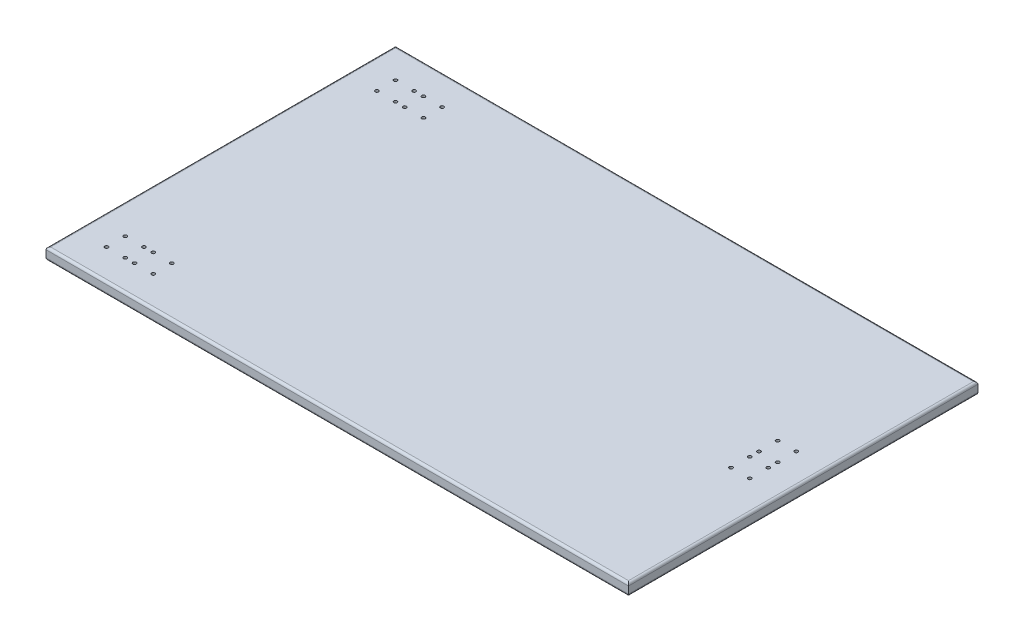
from build123d import *

# Parameters (mm, degrees)
ESQUISSE1_W             = 2500
ESQUISSE1_H             = 1500
BOSS_EXTRU_1_DEPTH      = 50
CONG_1_R                = 10
CONG_2_R                = 10
ESQUISSE4_R             = 7.25
ENL_V_MAT_EXTRU_2_DEPTH = 51
ESQUISSE5_R             = 7.25
ENL_V_MAT_EXTRU_3_DEPTH = 51


with BuildPart() as part:
    # Esquisse1 → Boss.-Extru.1 (new body)
    with BuildSketch(Plane(origin=(0, 0, 0), x_dir=(1, 0, 0), z_dir=(0, 1, 0))):
        Rectangle(ESQUISSE1_W, ESQUISSE1_H)
    extrude(amount=BOSS_EXTRU_1_DEPTH)

    # Congé1
    cong_1_edges = [part.edges().sort_by_distance(p)[0] for p in [
        (1250, 50, 0),
        (0, 50, -750),
        (-1250, 50, 0),
        (0, 50, 750),
    ]]
    fillet(cong_1_edges, radius=CONG_1_R)

    # Congé2
    cong_2_edges = [part.edges().sort_by_distance(p)[0] for p in [
        (0, 0, -750),
        (1250, 0, 0),
        (0, 0, 750),
        (-1250, 0, 0),
    ]]
    fillet(cong_2_edges, radius=CONG_2_R)

    # Esquisse4 → Enlèv. mat.-Extru.2 (cut, through all)
    with BuildSketch(Plane.XZ):
        with Locations((1120, -100)):
            Circle(ESQUISSE4_R)
        with Locations((1040, -100)):
            Circle(ESQUISSE4_R)
        with Locations((1040, -20)):
            Circle(ESQUISSE4_R)
        with Locations((1120, -20)):
            Circle(ESQUISSE4_R)
        with Locations((1120, 100)):
            Circle(ESQUISSE4_R)
        with Locations((1120, 20)):
            Circle(ESQUISSE4_R)
        with Locations((1040, 20)):
            Circle(ESQUISSE4_R)
        with Locations((1040, 100)):
            Circle(ESQUISSE4_R)
    extrude(amount=-ENL_V_MAT_EXTRU_2_DEPTH, mode=Mode.SUBTRACT)

    # Esquisse5 → Enlèv. mat.-Extru.3 (cut, through all)
    with BuildSketch(Plane(origin=(0, 0, 0), x_dir=(-1, 0, 0), z_dir=(0, -1, 0))):
        with Locations((1120, 620)):
            Circle(ESQUISSE5_R)
        with Locations((1040, 620)):
            Circle(ESQUISSE5_R)
        with Locations((1040, 540)):
            Circle(ESQUISSE5_R)
        with Locations((1120, 540)):
            Circle(ESQUISSE5_R)
        with Locations((920, 620)):
            Circle(ESQUISSE5_R)
        with Locations((1000, 620)):
            Circle(ESQUISSE5_R)
        with Locations((1000, 540)):
            Circle(ESQUISSE5_R)
        with Locations((920, 540)):
            Circle(ESQUISSE5_R)
        with Locations((920, -620)):
            Circle(ESQUISSE5_R)
        with Locations((920, -540)):
            Circle(ESQUISSE5_R)
        with Locations((1000, -540)):
            Circle(ESQUISSE5_R)
        with Locations((1000, -620)):
            Circle(ESQUISSE5_R)
        with Locations((1040, -620)):
            Circle(ESQUISSE5_R)
        with Locations((1040, -540)):
            Circle(ESQUISSE5_R)
        with Locations((1120, -540)):
            Circle(ESQUISSE5_R)
        with Locations((1120, -620)):
            Circle(ESQUISSE5_R)
    extrude(amount=-ENL_V_MAT_EXTRU_3_DEPTH, mode=Mode.SUBTRACT)


solid = part.part
